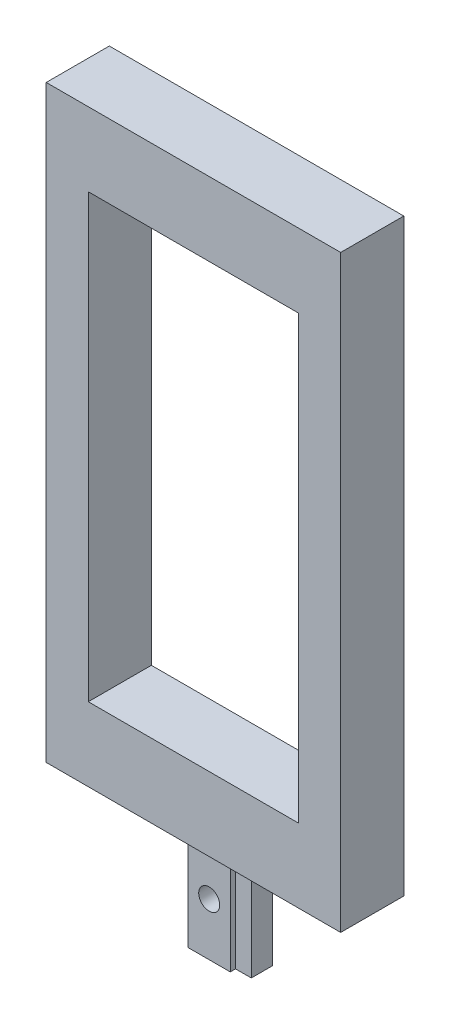
from build123d import *

# Parameters (mm, degrees)
SKETCH1_W           = 28
SKETCH1_H           = 56
SKETCH1_W_2         = 20
SKETCH1_H_2         = 42
BOSS_EXTRUDE1_DEPTH = 6
SKETCH2_W           = 4
SKETCH2_H           = 3
SKETCH2_W_2         = 1.5
SKETCH2_H_2         = 2
BOSS_EXTRUDE2_DEPTH = 10
SKETCH3_R           = 1
CUT_EXTRUDE1_DEPTH  = 10


with BuildPart() as part:
    # Sketch1 → Boss-Extrude1 (new body)
    with BuildSketch(Plane.XY):
        Rectangle(SKETCH1_W, SKETCH1_H)
        Rectangle(SKETCH1_W_2, SKETCH1_H_2, mode=Mode.SUBTRACT)
    extrude(amount=BOSS_EXTRUDE1_DEPTH)

    # Sketch2 → Boss-Extrude2 (add)
    with BuildSketch(Plane.XZ.offset(28)):
        with Locations((0, 3)):
            Rectangle(SKETCH2_W, SKETCH2_H)
        with Locations((2.75, 3)):
            Rectangle(SKETCH2_W_2, SKETCH2_H_2)
    extrude(amount=BOSS_EXTRUDE2_DEPTH)

    # Sketch3 → Cut-Extrude1 (cut)
    with BuildSketch(Plane.XY.offset(4.5)):
        with Locations((0, -33)):
            Circle(SKETCH3_R)
    extrude(amount=-CUT_EXTRUDE1_DEPTH, mode=Mode.SUBTRACT)


solid = part.part
